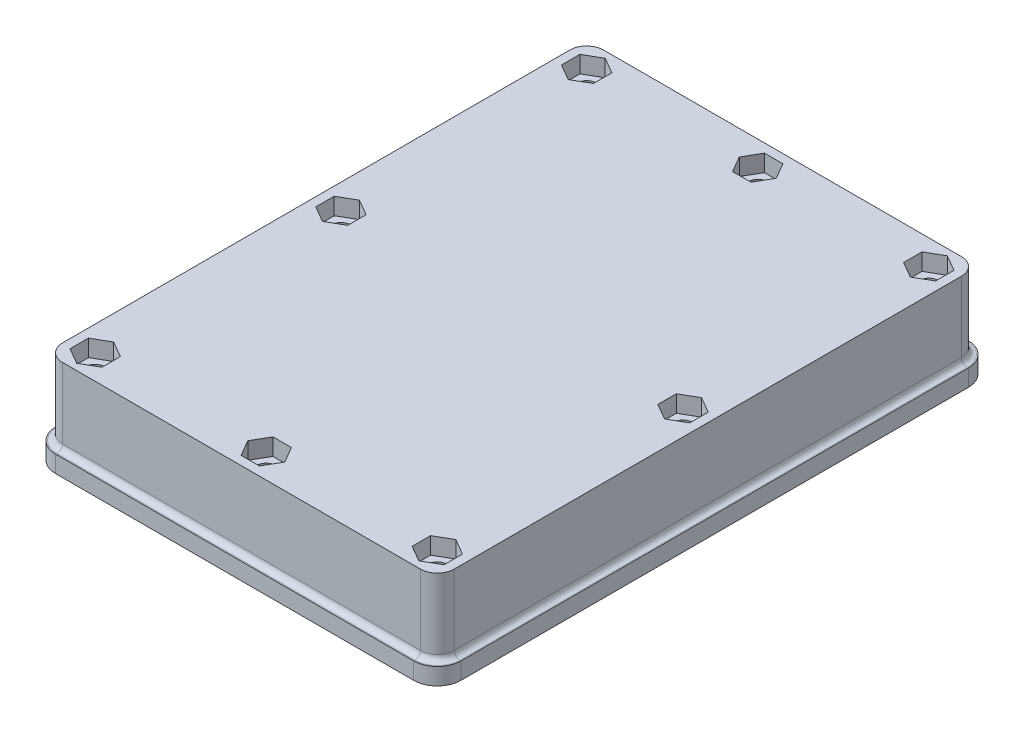
from build123d import *

# Parameters (mm, degrees)
SKETCH_1_R             = 1.7
EXTRUDE_1_DEPTH        = 12.5
SKETCH_2_R             = 1.7
EXTRUDE_2_DEPTH        = 2
EXTRUDE_START          = -2.5
EXTRUDE_5_DEPTH        = 2
EXTRUDE_1_2_DEPTH      = 2
EXTRUDE_3_DEPTH        = 3
FILLET_4_R             = 1
CUT_EXTRUDE_1_DEPTH    = 12.5
SKETCH_13_W            = 54.4
SKETCH_13_H            = 34.5
CUT_EXTRUDE_2_DEPTH    = 12.5
CUT_EXTRUDE_3_DEPTH    = 12.5
CUT_EXTRUDE_5_DEPTH    = 3
EXTRUDE_11_DEPTH       = 3
SKETCH_22_R            = 0.5
CUT_EXTRUDE_7_DEPTH    = 1
SKETCH_23_W            = 6.45
SKETCH_23_H            = 34.5
EXTRUDE_12_DEPTH       = 0.5
EXTRUDE_13_DEPTH       = 3
CHAMFER_2_SIZE         = 2
CHAMFER_2_SIZE2        = 0.535898385
CHAMFER_2_PART_2_SIZE  = 2
CHAMFER_2_PART_2_SIZE2 = 0.535898385
FILLET_7_R             = 3


with BuildPart() as part:
    # Эскиз1 → Extrude 1 (new body)
    with BuildSketch(Plane(origin=(0, 0, 0), x_dir=(1, 0, 0), z_dir=(0, 1, 0))):
        with BuildLine():
            ThreePointArc((-25.999265675, -44.551130115), (-25.120586019, -46.672450458), (-22.999265675, -47.551130115))
            Line((-22.999265675, -47.551130115), (40.500734325, -47.551130115))
            ThreePointArc((40.500734325, -47.551130115), (42.622054669, -46.672450458), (43.500734325, -44.551130115))
            Line((43.500734325, -44.551130115), (43.500734325, 45.448869885))
            ThreePointArc((43.500734325, 45.448869885), (42.622054669, 47.570190229), (40.500734325, 48.448869885))
            Line((40.500734325, 48.448869885), (-22.999265675, 48.448869885))
            ThreePointArc((-22.999265675, 48.448869885), (-25.120586019, 47.570190229), (-25.999265675, 45.448869885))
            Line((-25.999265675, 45.448869885), (-25.999265675, -44.551130115))
        make_face()
        with Locations((-21.599265675, -43.151130115)):
            Circle(SKETCH_1_R, mode=Mode.SUBTRACT)
        with Locations((8.750734325, -43.151130115)):
            Circle(SKETCH_1_R, mode=Mode.SUBTRACT)
        with Locations((-21.599265675, 0.448869885)):
            Circle(SKETCH_1_R, mode=Mode.SUBTRACT)
        with Locations((39.100734325, -43.151130115)):
            Circle(SKETCH_1_R, mode=Mode.SUBTRACT)
        with Locations((39.100734325, 0.448869885)):
            Circle(SKETCH_1_R, mode=Mode.SUBTRACT)
        with Locations((-21.599265675, 44.048869885)):
            Circle(SKETCH_1_R, mode=Mode.SUBTRACT)
        with Locations((8.750734325, 44.048869885)):
            Circle(SKETCH_1_R, mode=Mode.SUBTRACT)
        Polygon((-15.999265675, -31.551130115), (-15.999265675, 40.448869885), (38.000734325, 40.448869885), (38.000734325, 10.448869885), (35.500734325, 10.448869885), (35.500734325, -29.051130115), (35.500734325, -30.051130115), (35.500734325, -39.551130115), (27.500734325, -39.551130115), (27.500734325, -30.051130115), (21.000734325, -30.051130115), (21.000734325, -31.551130115), align=None, mode=Mode.SUBTRACT)
        with Locations((39.100734325, 44.048869885)):
            Circle(SKETCH_1_R, mode=Mode.SUBTRACT)
    extrude(amount=EXTRUDE_1_DEPTH)

    # Эскиз2 → Бобышка-Вытянуть2 (add)
    with BuildSketch(Plane(origin=(0, 12.5, 0), x_dir=(1, 0, 0), z_dir=(0, 1, 0))):
        with BuildLine():
            Line((-22.999265675, -47.551130115), (40.500734325, -47.551130115))
            ThreePointArc((40.500734325, -47.551130115), (42.622054669, -46.672450458), (43.500734325, -44.551130115))
            Line((43.500734325, -44.551130115), (43.500734325, 45.448869885))
            ThreePointArc((43.500734325, 45.448869885), (42.622054669, 47.570190229), (40.500734325, 48.448869885))
            Line((40.500734325, 48.448869885), (-22.999265675, 48.448869885))
            ThreePointArc((-22.999265675, 48.448869885), (-25.120586019, 47.570190229), (-25.999265675, 45.448869885))
            Line((-25.999265675, 45.448869885), (-25.999265675, -44.551130115))
            ThreePointArc((-25.999265675, -44.551130115), (-25.120586019, -46.672450458), (-22.999265675, -47.551130115))
        make_face()
        with Locations((39.100734325, -43.151130115)):
            Circle(SKETCH_2_R, mode=Mode.SUBTRACT)
        with Locations((8.750734325, -43.151130115)):
            Circle(SKETCH_2_R, mode=Mode.SUBTRACT)
        with Locations((-21.599265675, -43.151130115)):
            Circle(SKETCH_2_R, mode=Mode.SUBTRACT)
        with Locations((-21.599265675, 0.448869885)):
            Circle(SKETCH_2_R, mode=Mode.SUBTRACT)
        with Locations((39.100734325, 0.448869885)):
            Circle(SKETCH_2_R, mode=Mode.SUBTRACT)
        with Locations((-21.599265675, 44.048869885)):
            Circle(SKETCH_2_R, mode=Mode.SUBTRACT)
        with Locations((8.750734325, 44.048869885)):
            Circle(SKETCH_2_R, mode=Mode.SUBTRACT)
        with Locations((39.100734325, 44.048869885)):
            Circle(SKETCH_2_R, mode=Mode.SUBTRACT)
    extrude(amount=EXTRUDE_2_DEPTH)

    # Эскиз8 → Бобышка-Вытянуть5 (add)
    with BuildSketch(Plane.XZ.offset(-10).offset(EXTRUDE_START)):
        with BuildLine():
            Line((35.500734325, -5.248869885), (35.500734325, 4.351130115))
            ThreePointArc((35.500734325, 4.351130115), (33.100734325, -0.448869885), (35.500734325, -5.248869885))
        make_face()
    extrude(amount=EXTRUDE_5_DEPTH)

    # Эскиз9 → Extrude 1 2 (add)
    with BuildSketch(Plane.XZ):
        with BuildLine():
            Line((-25.999265675, 44.551130115), (-25.999265675, -45.448869885))
            ThreePointArc((-25.999265675, -45.448869885), (-25.120586019, -47.570190229), (-22.999265675, -48.448869885))
            Line((-22.999265675, -48.448869885), (40.500734325, -48.448869885))
            ThreePointArc((40.500734325, -48.448869885), (42.622054669, -47.570190229), (43.500734325, -45.448869885))
            Line((43.500734325, -45.448869885), (43.500734325, 44.551130115))
            ThreePointArc((43.500734325, 44.551130115), (42.622054669, 46.672450458), (40.500734325, 47.551130115))
            Line((40.500734325, 47.551130115), (-22.999265675, 47.551130115))
            ThreePointArc((-22.999265675, 47.551130115), (-25.120586019, 46.672450458), (-25.999265675, 44.551130115))
        make_face()
        with BuildLine():
            Line((-24.699265675, 44.551130115), (-24.699265675, -45.448869885))
            ThreePointArc((-24.699265675, -45.448869885), (-24.201347203, -46.650951413), (-22.999265675, -47.148869885))
            Line((-22.999265675, -47.148869885), (40.500734325, -47.148869885))
            ThreePointArc((40.500734325, -47.148869885), (41.702815853, -46.650951413), (42.200734325, -45.448869885))
            Line((42.200734325, -45.448869885), (42.200734325, 44.551130115))
            ThreePointArc((42.200734325, 44.551130115), (41.702815853, 45.753211643), (40.500734325, 46.251130115))
            Line((40.500734325, 46.251130115), (-22.999265675, 46.251130115))
            ThreePointArc((-22.999265675, 46.251130115), (-24.201347203, 45.753211643), (-24.699265675, 44.551130115))
        make_face(mode=Mode.SUBTRACT)
    extrude(amount=EXTRUDE_1_2_DEPTH)

    # Эскиз11 → Вытянуть-Тонкостенный3 (add)
    with BuildSketch(Plane.XZ.offset(2)):
        with BuildLine():
            Line((40.500734325, 48.751130115), (-22.999265675, 48.751130115))
            ThreePointArc((-22.999265675, 48.751130115), (-25.969114156, 47.520978596), (-27.199265675, 44.551130115))
            Line((-27.199265675, 44.551130115), (-27.199265675, -45.448869885))
            ThreePointArc((-27.199265675, -45.448869885), (-25.969114156, -48.418718366), (-22.999265675, -49.648869885))
            Line((-22.999265675, -49.648869885), (40.500734325, -49.648869885))
            ThreePointArc((40.500734325, -49.648869885), (43.470582806, -48.418718366), (44.700734325, -45.448869885))
            Line((44.700734325, -45.448869885), (44.700734325, 44.551130115))
            ThreePointArc((44.700734325, 44.551130115), (43.470582806, 47.520978596), (40.500734325, 48.751130115))
        make_face()
        with BuildLine():
            Line((40.500734325, 46.251130115), (-22.999265675, 46.251130115))
            ThreePointArc((-22.999265675, 46.251130115), (-24.201347203, 45.753211643), (-24.699265675, 44.551130115))
            Line((-24.699265675, 44.551130115), (-24.699265675, -45.448869885))
            ThreePointArc((-24.699265675, -45.448869885), (-24.201347203, -46.650951413), (-22.999265675, -47.148869885))
            Line((-22.999265675, -47.148869885), (40.500734325, -47.148869885))
            ThreePointArc((40.500734325, -47.148869885), (41.702815853, -46.650951413), (42.200734325, -45.448869885))
            Line((42.200734325, -45.448869885), (42.200734325, 44.551130115))
            ThreePointArc((42.200734325, 44.551130115), (41.702815853, 45.753211643), (40.500734325, 46.251130115))
        make_face(mode=Mode.SUBTRACT)
    extrude(amount=-EXTRUDE_3_DEPTH)

    # Скругление4
    fillet_4_edges = [part.edges().sort_by_distance(p)[0] for p in [
        (-25.999265675, 1, -0.448869885),
        (-25.120586019, 1, 46.672450458),
        (43.500734325, 1, -0.448869885),
        (8.750734325, 1, -48.448869885),
        (-25.120586019, 1, -47.570190229),
        (42.622054669, 1, -47.570190229),
        (42.622054669, 1, 46.672450458),
        (8.750734325, 1, 47.551130115),
    ]]
    fillet(fillet_4_edges, radius=FILLET_4_R)

    # Эскиз12 → Вырез-Вытянуть1 (cut)
    with BuildSketch(Plane.XZ):
        Polygon((-15.999265675, 31.551130115), (19.94284743, 28.85982003), (27.500734325, 28.85982003), (27.500734325, 38.451130115), (-15.999265675, 38.451130115), align=None)
    extrude(amount=-CUT_EXTRUDE_1_DEPTH, mode=Mode.SUBTRACT)

    # Эскиз13 → Вырез-Вытянуть2 (cut)
    with BuildSketch(Plane.XZ):
        with Locations((8.750734325, -23.198869885)):
            Rectangle(SKETCH_13_W, SKETCH_13_H)
    extrude(amount=-CUT_EXTRUDE_2_DEPTH, mode=Mode.SUBTRACT)

    # Эскиз14 → Вырез-Вытянуть3 (cut)
    with BuildSketch(Plane.XZ):
        Polygon((35.950734325, -40.448869885), (38.000734325, -40.448869885), (38.000734325, -5.948869885), (35.500734325, -5.948869885), align=None)
    extrude(amount=-CUT_EXTRUDE_3_DEPTH, mode=Mode.SUBTRACT)

    # Эскиз19 → Вырез-Вытянуть5 (cut)
    with BuildSketch(Plane(origin=(0, 14.5, 0), x_dir=(1, 0, 0), z_dir=(0, 1, 0))):
        Polygon((-21.599265675, 40.775293859), (-18.764265675, 42.412081872), (-18.764265675, 45.685657899), (-21.599265675, 47.322445912), (-24.434265675, 45.685657899), (-24.434265675, 42.412081872), align=None)
        Polygon((-21.599265675, -2.824706141), (-18.764265675, -1.187918128), (-18.764265675, 2.085657899), (-21.599265675, 3.722445912), (-24.434265675, 2.085657899), (-24.434265675, -1.187918128), align=None)
        Polygon((5.477158299, 44.048869885), (7.113946312, 41.213869885), (10.387522338, 41.213869885), (12.024310351, 44.048869885), (10.387522338, 46.883869885), (7.113946312, 46.883869885), align=None)
        Polygon((39.100734325, 40.775293859), (41.935734325, 42.412081872), (41.935734325, 45.685657899), (39.100734325, 47.322445912), (36.265734325, 45.685657899), (36.265734325, 42.412081872), align=None)
        Polygon((39.100734325, -2.824706141), (41.935734325, -1.187918128), (41.935734325, 2.085657899), (39.100734325, 3.722445912), (36.265734325, 2.085657899), (36.265734325, -1.187918128), align=None)
        Polygon((-21.599265675, -39.877554088), (-24.434265675, -41.514342101), (-24.434265675, -44.787918128), (-21.599265675, -46.424706141), (-18.764265675, -44.787918128), (-18.764265675, -41.514342101), align=None)
        Polygon((5.477158299, -43.151130115), (7.113946312, -45.986130115), (10.387522338, -45.986130115), (12.024310351, -43.151130115), (10.387522338, -40.316130115), (7.113946312, -40.316130115), align=None)
        Polygon((39.100734325, -39.877554088), (36.265734325, -41.514342101), (36.265734325, -44.787918128), (39.100734325, -46.424706141), (41.935734325, -44.787918128), (41.935734325, -41.514342101), align=None)
    extrude(amount=-CUT_EXTRUDE_5_DEPTH, mode=Mode.SUBTRACT)

    # Эскиз15 → Бобышка-Вытянуть11 (add)
    with BuildSketch(Plane(origin=(-18.449265675, 0, 0), x_dir=(0, 0, -1), z_dir=(1, 0, 0))):
        with BuildLine():
            Line((37.398869885, 5.9), (8.998869885, 5.9))
            ThreePointArc((8.998869885, 5.9), (7.001884318, 6.644669515), (5.980042537, 8.515050069))
            Line((5.980042537, 8.515050069), (5.948869885, 8.515050069))
            Line((5.948869885, 8.515050069), (5.948869885, 4))
            Line((5.948869885, 4), (40.448869885, 4))
            Line((40.448869885, 4), (40.448869885, 8.515050069))
            Line((40.448869885, 8.515050069), (40.417697234, 8.515050069))
            ThreePointArc((40.417697234, 8.515050069), (39.395855453, 6.644669515), (37.398869885, 5.9))
        make_face()
        with BuildLine():
            Line((5.948869885, 12.5), (40.448869885, 12.5))
            Line((40.448869885, 12.5), (40.448869885, 9.444640379))
            Line((40.448869885, 9.444640379), (40.408492934, 9.444640379))
            ThreePointArc((40.408492934, 9.444640379), (39.372932555, 11.274989587), (37.398869885, 12))
            Line((37.398869885, 12), (8.998869885, 12))
            ThreePointArc((8.998869885, 12), (7.024807216, 11.274989587), (5.989246837, 9.444640379))
            Line((5.989246837, 9.444640379), (5.948869885, 9.444640379))
            Line((5.948869885, 9.444640379), (5.948869885, 12.5))
        make_face()
    extrude(amount=EXTRUDE_11_DEPTH)

    # Эскиз22 → Вырез-Вытянуть7 (cut)
    with BuildSketch(Plane.XZ.offset(-4)):
        with Locations((-17.949265675, -35.948869885)):
            Circle(SKETCH_22_R)
        with Locations((-17.949265675, -29.148869885)):
            Circle(SKETCH_22_R)
    extrude(amount=-CUT_EXTRUDE_7_DEPTH, mode=Mode.SUBTRACT)

    # Эскиз23 → Бобышка-Вытянуть12 (add)
    with BuildSketch(Plane.XZ.offset(-12.5)):
        with Locations((34.775734325, -23.198869885)):
            Rectangle(SKETCH_23_W, SKETCH_23_H)
    extrude(amount=EXTRUDE_12_DEPTH)

    # Эскиз25 → Бобышка-Вытянуть13 (add)
    with BuildSketch(Plane.XZ.offset(-12.5)):
        with BuildLine():
            Line((4.481694746, -4.363151308), (6.790858434, -4.363151308))
            ThreePointArc((6.790858434, -4.363151308), (9.100734325, 0.551130115), (11.410610217, -4.363151308))
            Line((11.410610217, -4.363151308), (13.719773904, -4.363151308))
            ThreePointArc((13.719773904, -4.363151308), (9.100734325, 2.551130115), (4.481694746, -4.363151308))
        make_face()
    extrude(amount=EXTRUDE_13_DEPTH)

    # Фаска2
    chamfer_2_edges = [part.edges().sort_by_distance(p)[0] for p in [
        (12.56519206, 9.5, -4.363151308),
    ]]
    chamfer_2_side = [part.faces().sort_by_distance(p)[0] for p in [
        (12.56519206, 11, -4.363151308),
    ]]
    chamfer(chamfer_2_edges, length=CHAMFER_2_SIZE, length2=CHAMFER_2_SIZE2, reference=chamfer_2_side[0])

    # Фаска2 part 2
    chamfer_2_part_2_edges = [part.edges().sort_by_distance(p)[0] for p in [
        (5.63627659, 9.5, -4.363151308),
    ]]
    chamfer_2_part_2_side = [part.faces().sort_by_distance(p)[0] for p in [
        (5.63627659, 11, -4.363151308),
    ]]
    chamfer(chamfer_2_part_2_edges, length=CHAMFER_2_PART_2_SIZE, length2=CHAMFER_2_PART_2_SIZE2, reference=chamfer_2_part_2_side[0])

    # Скругление7
    fillet_7_edges = [part.edges().sort_by_distance(p)[0] for p in [
        (8.050734325, 12.5, -40.448869885),
    ]]
    fillet(fillet_7_edges, radius=FILLET_7_R)


solid = part.part
